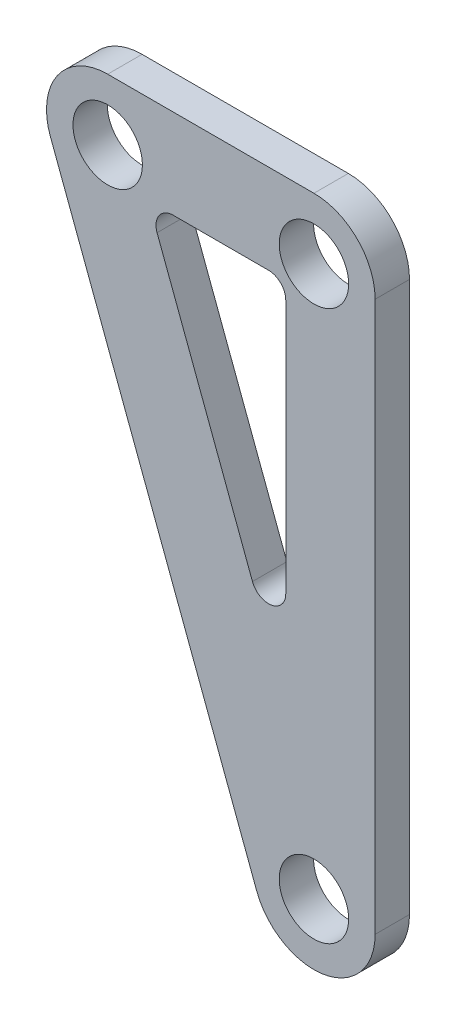
from build123d import *

# Parameters (mm, degrees)
ESQUISSE1_R        = 6.4135
BOSS_EXTRU_1_DEPTH = 6.35
CONG_1_R           = 3.175


with BuildPart() as part:
    # Esquisse1 → Boss.-Extru.1 (new body)
    with BuildSketch(Plane.XY):
        with BuildLine():
            Line((-10.583328694, -3.96874826), (27.516671306, -105.56874826))
            ThreePointArc((27.516671306, -105.56874826), (40.116735576, -112.721626977), (49.403, -101.6))
            Line((49.403, -101.6), (49.403, 0))
            ThreePointArc((49.403, 0), (46.092427948, 7.992427948), (38.1, 11.303))
            Line((38.1, 11.303), (0, 11.303))
            ThreePointArc((0, 11.303), (-9.290225255, 6.438130451), (-10.583328694, -3.96874826))
        make_face()
        Circle(ESQUISSE1_R, mode=Mode.SUBTRACT)
        with Locations((38.1, 0)):
            Circle(ESQUISSE1_R, mode=Mode.SUBTRACT)
        with Locations((38.1, -101.6)):
            Circle(ESQUISSE1_R, mode=Mode.SUBTRACT)
        Polygon((7.513703438, -5.207), (32.893, -72.885124166), (32.893, -5.207), align=None, mode=Mode.SUBTRACT)
    extrude(amount=BOSS_EXTRU_1_DEPTH)

    # Congé1
    cong_1_edges = [part.edges().sort_by_distance(p)[0] for p in [
        (32.893, -5.207, 3.175),
        (7.513703438, -5.207, 3.175),
        (32.893, -72.885124166, 3.175),
    ]]
    fillet(cong_1_edges, radius=CONG_1_R)


solid = part.part
